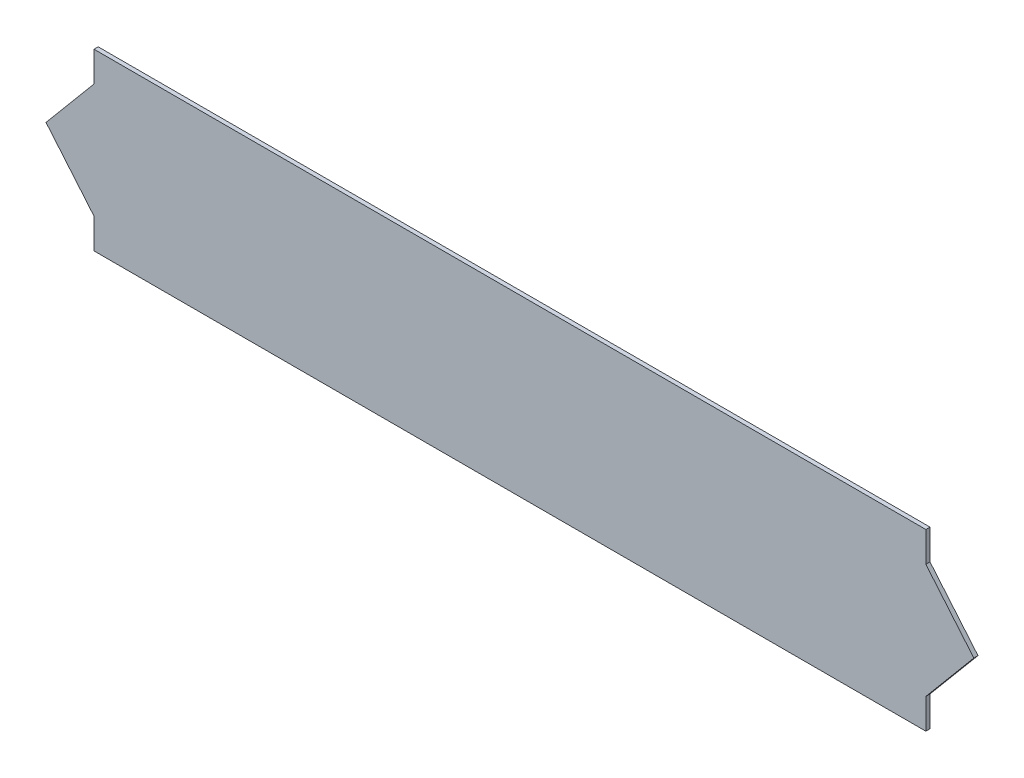
from build123d import *

# Parameters (mm, degrees)
BOSS_EXTRUDE1_DEPTH = 2


with BuildPart() as part:
    # Sketch1 → Boss-Extrude1 (new body)
    with BuildSketch(Plane.XY):
        Polygon((200, 0), (-200, 0), (-200, -14.5), (-223.075239857, -42), (-200, -69.5), (-200, -84), (200, -84), (200, -69.5), (223.075239857, -42), (200, -14.5), align=None)
    extrude(amount=BOSS_EXTRUDE1_DEPTH)


solid = part.part
